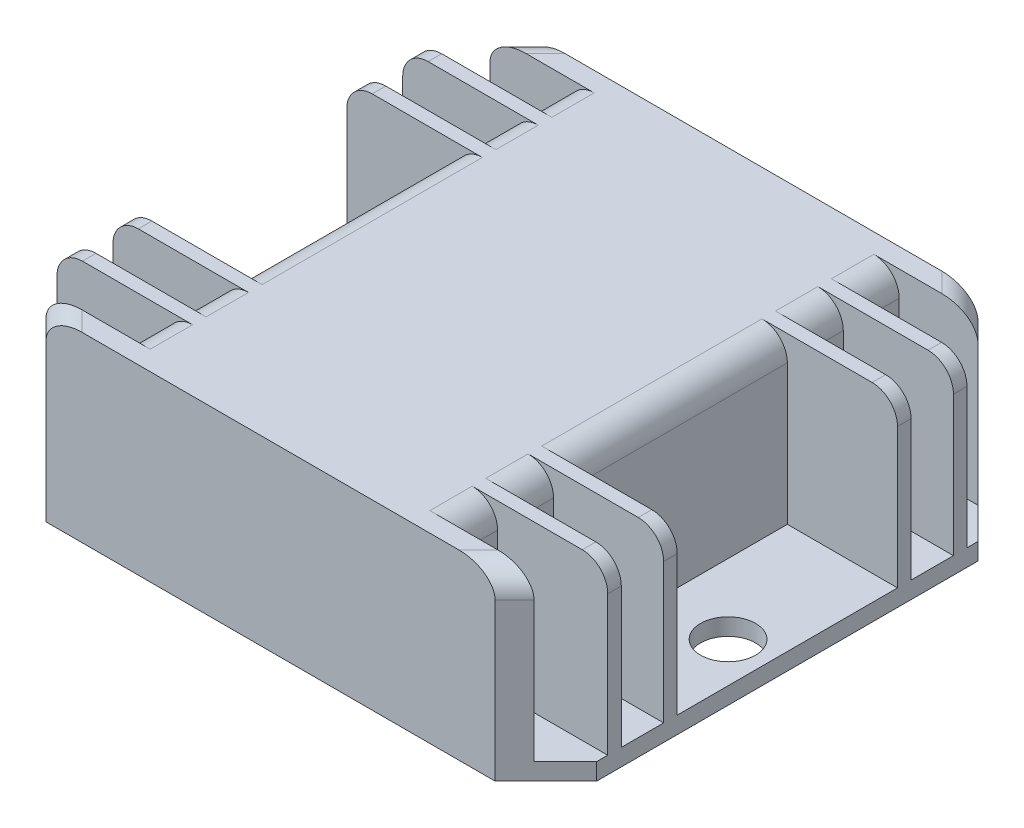
from build123d import *

# Parameters (mm, degrees)
SKETCH1_W           = 65
SKETCH1_H           = 57
SKETCH1_R           = 3.25
BOSS_EXTRUDE1_DEPTH = 21.5
CHAMFER1_SIZE       = 6
SKETCH2_W           = 13
SKETCH2_H           = 26
SKETCH2_H_2         = 5
CUT_EXTRUDE1_DEPTH  = 19.5
FILLET1_R           = 3


with BuildPart() as part:
    # Sketch1 → Boss-Extrude1 (new body)
    with BuildSketch(Plane(origin=(0, 0, 0), x_dir=(1, 0, 0), z_dir=(0, 1, 0))):
        Rectangle(SKETCH1_W, SKETCH1_H)
        with Locations((27.75, -2.25)):
            Circle(SKETCH1_R, mode=Mode.SUBTRACT)
        with Locations((-27.75, -2.25)):
            Circle(SKETCH1_R, mode=Mode.SUBTRACT)
    extrude(amount=BOSS_EXTRUDE1_DEPTH)

    # Chamfer1
    chamfer1_edges = [part.edges().sort_by_distance(p)[0] for p in [
        (32.5, 10.75, 28.5),
        (-32.5, 10.75, 28.5),
        (-32.5, 10.75, -28.5),
        (32.5, 10.75, -28.5),
    ]]
    chamfer(chamfer1_edges, length=CHAMFER1_SIZE)

    # Sketch2 → Cut-Extrude1 (cut)
    with BuildSketch(Plane(origin=(0, 21.5, 0), x_dir=(1, 0, 0), z_dir=(0, 1, 0))):
        with Locations((-26, 0)):
            Rectangle(SKETCH2_W, SKETCH2_H)
        with Locations((-26, 17.1)):
            Rectangle(SKETCH2_W, SKETCH2_H_2)
        with Locations((-26, 23.7)):
            Rectangle(SKETCH2_W, SKETCH2_H_2)
        with Locations((-26, -17.1)):
            Rectangle(SKETCH2_W, SKETCH2_H_2)
        with Locations((-26, -23.7)):
            Rectangle(SKETCH2_W, SKETCH2_H_2)
        with Locations((26, -23.7)):
            Rectangle(SKETCH2_W, SKETCH2_H_2)
        with Locations((26, -17.1)):
            Rectangle(SKETCH2_W, SKETCH2_H_2)
        with Locations((26, 0)):
            Rectangle(SKETCH2_W, SKETCH2_H)
        with Locations((26, 17.1)):
            Rectangle(SKETCH2_W, SKETCH2_H_2)
        with Locations((26, 23.7)):
            Rectangle(SKETCH2_W, SKETCH2_H_2)
    extrude(amount=-CUT_EXTRUDE1_DEPTH, mode=Mode.SUBTRACT)

    # Fillet1
    fillet1_edges = [part.edges().sort_by_distance(p)[0] for p in [
        (-19.5, 21.5, 17.1),
        (-19.5, 21.5, 23.7),
        (19.5, 21.5, 23.7),
        (19.5, 21.5, 17.1),
        (19.5, 21.5, 0),
        (19.5, 21.5, -17.1),
        (19.5, 21.5, -23.7),
        (-19.5, 21.5, 0),
        (-27.65, 21.5, -27.35),
        (27.65, 21.5, 27.35),
        (-27.65, 21.5, 27.35),
        (27.65, 21.5, -27.35),
        (-32.5, 21.5, -20.4),
        (-32.5, 21.5, -13.8),
        (-32.5, 21.5, 13.8),
        (-32.5, 21.5, 20.4),
        (32.5, 21.5, 20.4),
        (32.5, 21.5, 13.8),
        (32.5, 21.5, -13.8),
        (32.5, 21.5, -20.4),
        (-19.5, 21.5, -17.1),
        (-19.5, 21.5, -23.7),
    ]]
    fillet(fillet1_edges, radius=FILLET1_R)


solid = part.part
